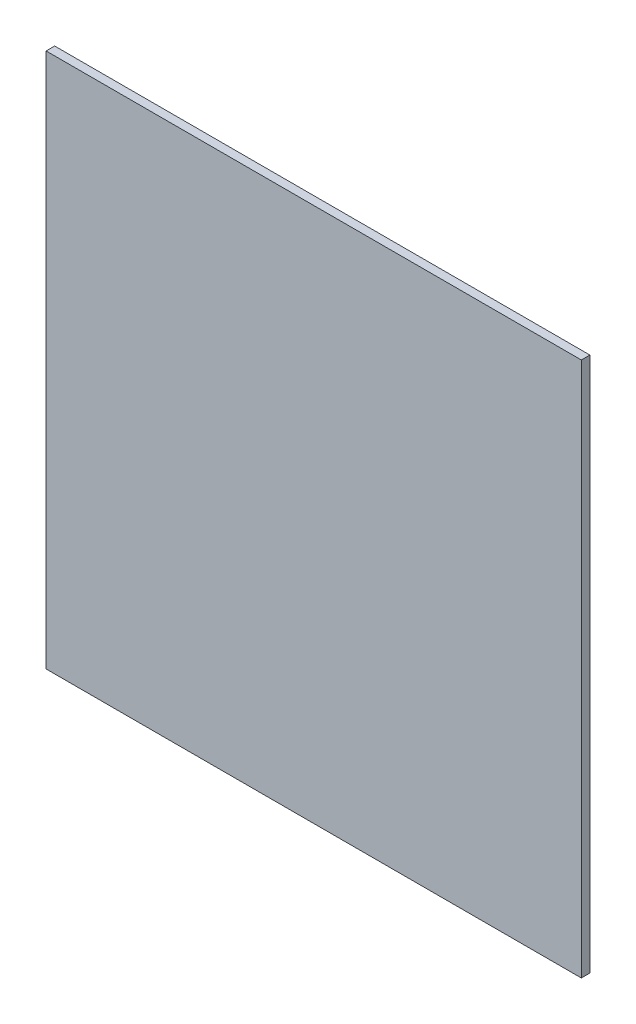
from build123d import *

# Parameters (mm, degrees)
ESBO_O1_W                = 125
ESBO_O1_H                = 125
RESSALTO_EXTRUS_O1_DEPTH = 2


with BuildPart() as part:
    # Esboço1 → Ressalto-extrusão1 (new body)
    with BuildSketch(Plane.XY):
        Rectangle(ESBO_O1_W, ESBO_O1_H)
    extrude(amount=RESSALTO_EXTRUS_O1_DEPTH)


solid = part.part
